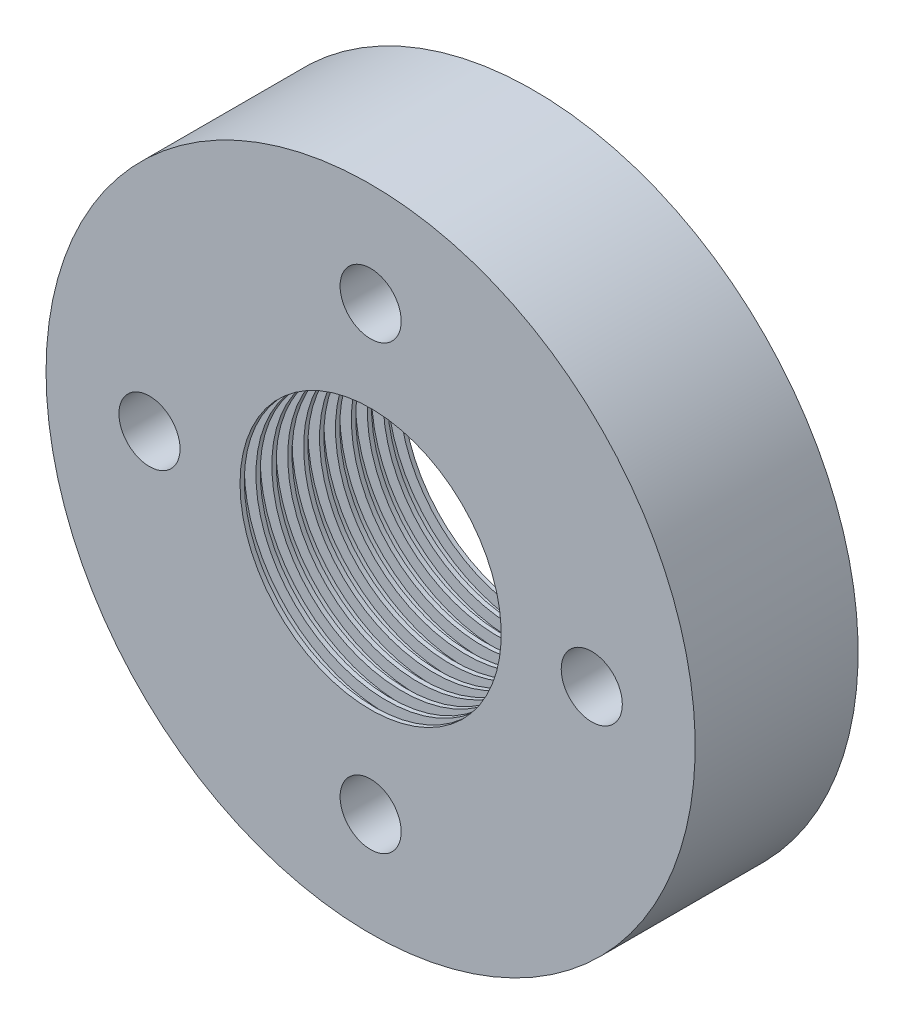
from build123d import *

# Parameters (mm, degrees)
SKETCH1_W                       = 10.668
SKETCH1_H                       = 12.7
SKETCH2_W                       = 0.762
SKETCH2_H                       = 0.762
LPATTERN1_COUNT                 = 10
LPATTERN1_PITCH                 = 1.0414
M4X0_7_TAPPED_HOLE1_D           = 4
M4X0_7_TAPPED_HOLE1_DEPTH       = 10.668
M4X0_7_TAPPED_HOLE1_CSINK_D     = 4.05
M4X0_7_TAPPED_HOLE1_CSINK_ANGLE = 90
CIRPATTERN1_COUNT               = 4


with BuildPart() as part:
    # Sketch1 → Revolve1 (revolve)
    with BuildSketch(Plane(origin=(0, 0, 0), x_dir=(0, 0, -1), z_dir=(1, 0, 0))):
        with Locations((-5.334, 14.9008)):
            Rectangle(SKETCH1_W, SKETCH1_H)
    revolve(axis=Axis((0, 0, 0), (0, 0, 1)))

    # Sketch2 → Cut-Revolve1 (revolve, cut)
    with BuildSketch(Plane(origin=(0, 0, 0), x_dir=(0, 0, -1), z_dir=(1, 0, 0))):
        with Locations((-0.635, 8.9318)):
            Rectangle(SKETCH2_W, SKETCH2_H)
    cut_revolve1 = revolve(axis=Axis((0, 0, 10.668), (0, 0, -1)), mode=Mode.SUBTRACT)

    # LPattern1: Cut-Revolve1 ×10
    with Locations(*[(0, 0, i * LPATTERN1_PITCH) for i in range(1, LPATTERN1_COUNT)]):
        add(cut_revolve1, mode=Mode.SUBTRACT)

    # M4x0.7 Tapped Hole1
    with Locations(Plane(origin=(0, 0, 0), x_dir=(-1, 0, 0), z_dir=(0, 0, -1))):
        with Locations((0, 14.478)):
            m4x0_7_tapped_hole1 = CounterSinkHole(M4X0_7_TAPPED_HOLE1_D / 2, M4X0_7_TAPPED_HOLE1_CSINK_D / 2, depth=M4X0_7_TAPPED_HOLE1_DEPTH, counter_sink_angle=M4X0_7_TAPPED_HOLE1_CSINK_ANGLE)

    # CirPattern1: M4x0.7 Tapped Hole1 ×4 about axis
    cirpattern1_axis = Axis((0, 0, 0), (0, 0, 1))
    for i in range(1, CIRPATTERN1_COUNT):
        add(m4x0_7_tapped_hole1.rotate(cirpattern1_axis, i * 360 / CIRPATTERN1_COUNT), mode=Mode.SUBTRACT)


solid = part.part
